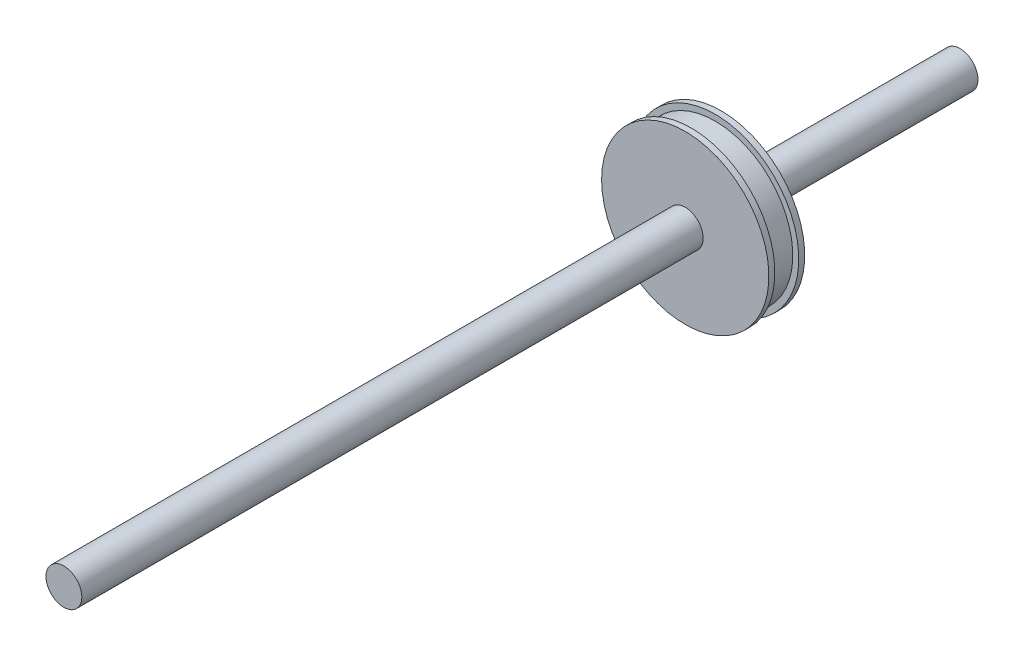
from build123d import *

# Parameters (mm, degrees)
SKETCH1_R           = 1.5
BOSS_EXTRUDE1_DEPTH = 75


with BuildPart() as part:
    # Sketch1 → Boss-Extrude1 (new body)
    with BuildSketch(Plane.XY):
        Circle(SKETCH1_R)
    extrude(amount=BOSS_EXTRUDE1_DEPTH)


with BuildPart() as body_2:
    # Sketch2 → Revolve1 (revolve)
    with BuildSketch(Plane(origin=(0, 0, 0), x_dir=(1, 0, 0), z_dir=(0, 1, 0))):
        Polygon((7, -20), (7, -20.5), (6.5, -20.5), (6.5, -22.5), (7, -22.5), (7, -23), (0, -23), (0, -20), align=None)
    revolve(axis=Axis((0, 0, 20), (0, 0, 1)))


solid = Compound([part.part, body_2.part])
